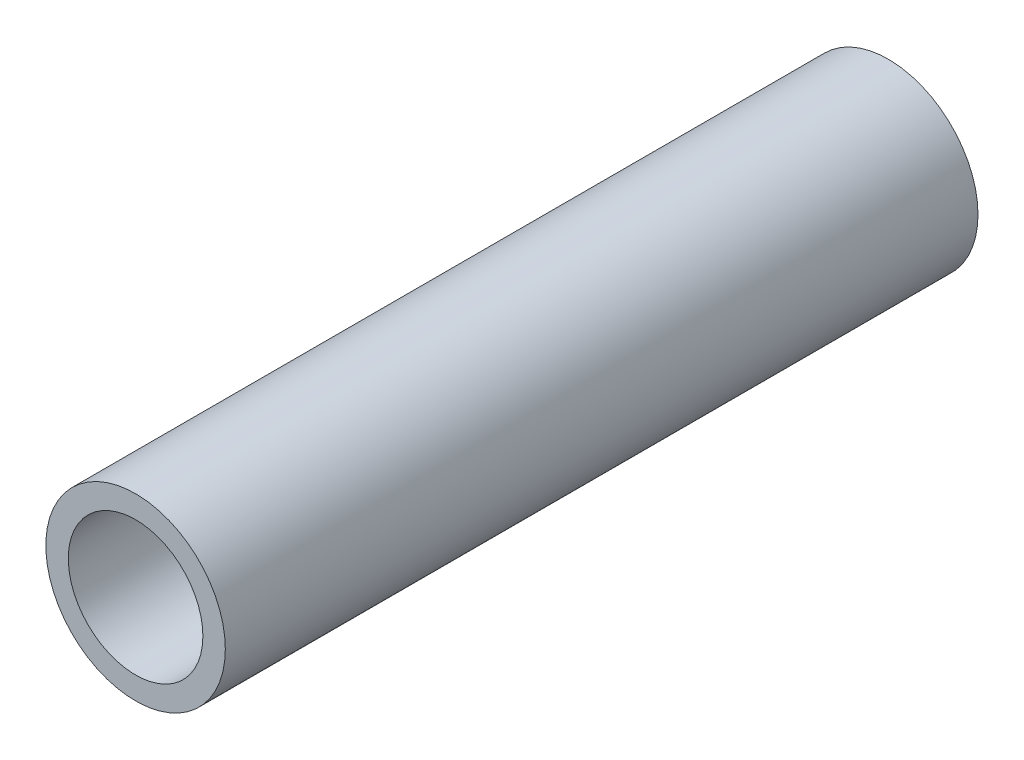
from build123d import *

# Parameters (mm, degrees)
SKETCH1_R           = 4
SKETCH1_R_2         = 3
BOSS_EXTRUDE1_DEPTH = 33.55


with BuildPart() as part:
    # Sketch1 → Boss-Extrude1 (new body)
    with BuildSketch(Plane.XY):
        Circle(SKETCH1_R)
        Circle(SKETCH1_R_2, mode=Mode.SUBTRACT)
    extrude(amount=BOSS_EXTRUDE1_DEPTH)


solid = part.part
